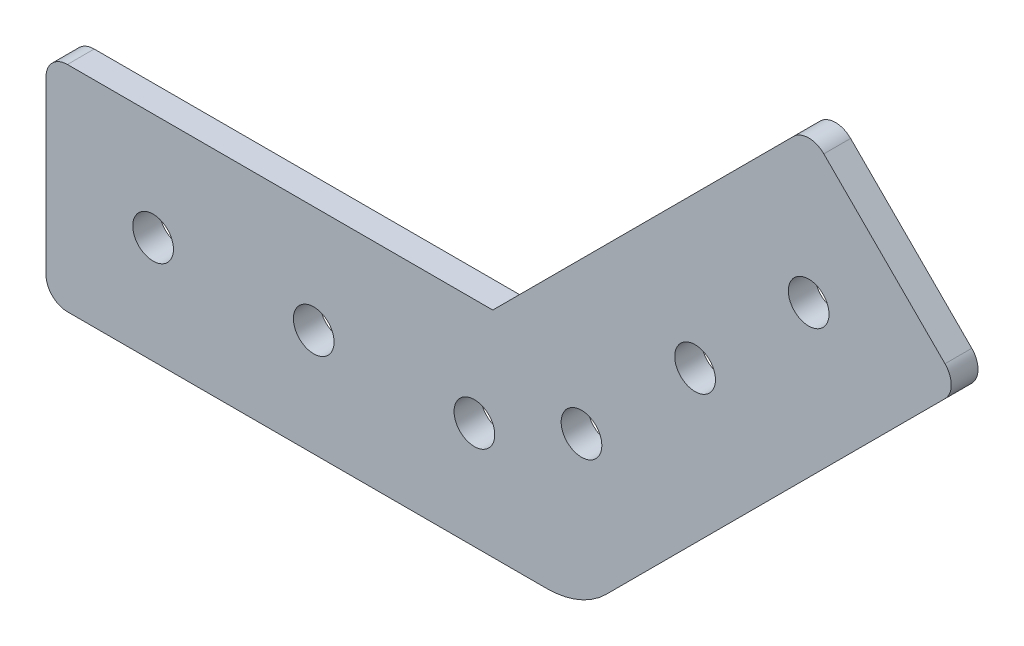
from build123d import *

# Parameters (mm, degrees)
SKETCH1_R           = 2.413
BOSS_EXTRUDE1_DEPTH = 3.175
FILLET1_R           = 10
FILLET2_R           = 2.54
FILLET3_R           = 2.54


with BuildPart() as part:
    # Sketch1 → Boss-Extrude1 (new body)
    with BuildSketch(Plane.XY):
        Polygon((0, 0), (63.5, 0), (108.401280605, 44.901280605), (90.440768363, 62.861792847), (52.978975516, 25.4), (0, 25.4), align=None)
        with Locations((12.7, 12.7)):
            Circle(SKETCH1_R, mode=Mode.SUBTRACT)
        with Locations((31.75, 12.7)):
            Circle(SKETCH1_R, mode=Mode.SUBTRACT)
        with Locations((76.970384182, 31.430896424)):
            Circle(SKETCH1_R, mode=Mode.SUBTRACT)
        with Locations((90.440768363, 44.901280605)):
            Circle(SKETCH1_R, mode=Mode.SUBTRACT)
        with Locations((50.8, 12.7)):
            Circle(SKETCH1_R, mode=Mode.SUBTRACT)
        with Locations((63.5, 17.960512242)):
            Circle(SKETCH1_R, mode=Mode.SUBTRACT)
    extrude(amount=BOSS_EXTRUDE1_DEPTH)

    # Fillet1
    fillet1_edges = [part.edges().sort_by_distance(p)[0] for p in [
        (63.5, 0, 1.5875),
    ]]
    fillet(fillet1_edges, radius=FILLET1_R)

    # Fillet2
    fillet2_edges = [part.edges().sort_by_distance(p)[0] for p in [
        (0, 25.4, 1.5875),
    ]]
    fillet(fillet2_edges, radius=FILLET2_R)

    # Fillet3
    fillet3_edges = [part.edges().sort_by_distance(p)[0] for p in [
        (90.440768363, 62.861792847, 1.5875),
        (108.401280605, 44.901280605, 1.5875),
        (0, 0, 1.5875),
    ]]
    fillet(fillet3_edges, radius=FILLET3_R)


solid = part.part
